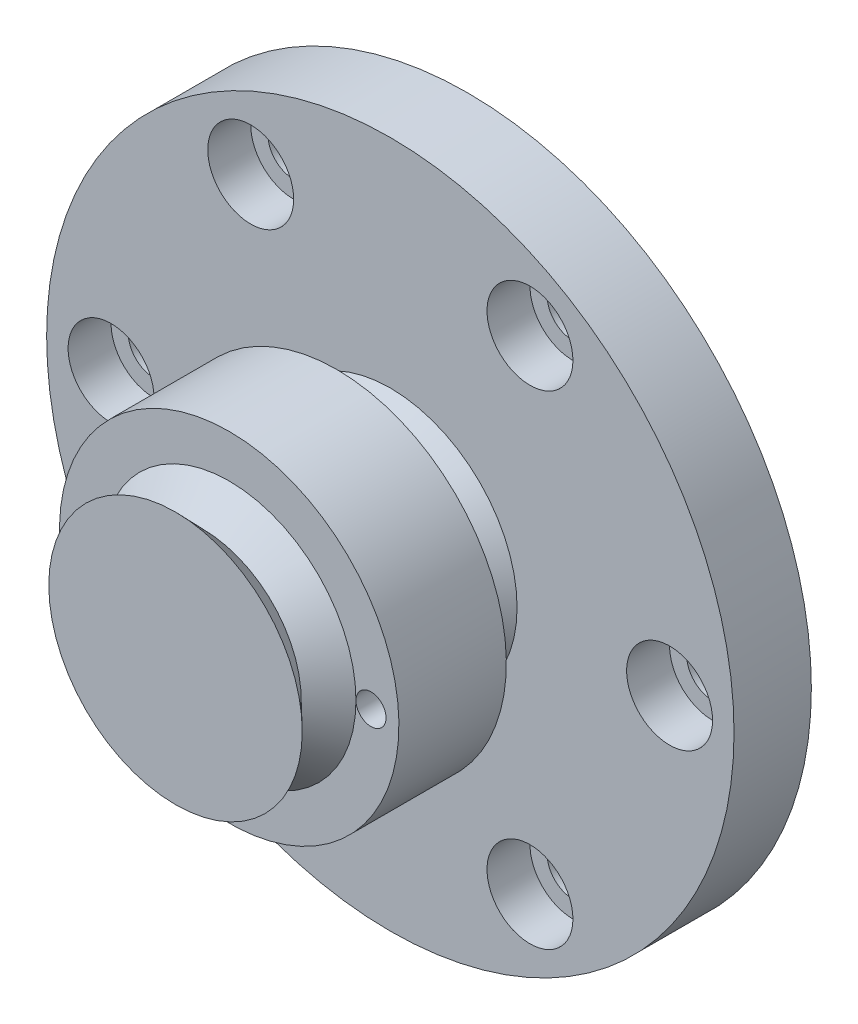
from build123d import *

# Parameters (mm, degrees)
SKETCH_1_R          = 16
SKETCH_1_R_2        = 1.2
EXTRUDE_1_DEPTH     = 3.6
SKETCH_2_R          = 2
CUT_EXTRUDE_1_DEPTH = 2
SKETCH_3_R          = 1
CUT_EXTRUDE_2_DEPTH = 2
SKETCH_4_R          = 7.9
EXTRUDE_2_DEPTH     = 10
SKETCH_6_R          = 0.7
CUT_EXTRUDE_3_DEPTH = 5


with BuildPart() as part:
    # 스케치1 → 보스-돌출1 (new body)
    with BuildSketch(Plane.XY):
        Circle(SKETCH_1_R)
        with Locations((13, 0)):
            Circle(SKETCH_1_R_2, mode=Mode.SUBTRACT)
        with Locations((6.5, -11.258330249)):
            Circle(SKETCH_1_R_2, mode=Mode.SUBTRACT)
        with Locations((-6.5, -11.258330249)):
            Circle(SKETCH_1_R_2, mode=Mode.SUBTRACT)
        with Locations((-13, 0)):
            Circle(SKETCH_1_R_2, mode=Mode.SUBTRACT)
        with Locations((-6.5, 11.258330249)):
            Circle(SKETCH_1_R_2, mode=Mode.SUBTRACT)
        with Locations((6.5, 11.258330249)):
            Circle(SKETCH_1_R_2, mode=Mode.SUBTRACT)
    extrude(amount=EXTRUDE_1_DEPTH)

    # 스케치2 → 컷-돌출1 (cut)
    with BuildSketch(Plane.XY.offset(3.6)):
        with Locations((13, 0)):
            Circle(SKETCH_2_R)
        with Locations((6.5, -11.258330249)):
            Circle(SKETCH_2_R)
        with Locations((-6.5, -11.258330249)):
            Circle(SKETCH_2_R)
        with Locations((-13, 0)):
            Circle(SKETCH_2_R)
        with Locations((-6.5, 11.258330249)):
            Circle(SKETCH_2_R)
        with Locations((6.5, 11.258330249)):
            Circle(SKETCH_2_R)
    extrude(amount=-CUT_EXTRUDE_1_DEPTH, mode=Mode.SUBTRACT)

    # 스케치3 → 컷-돌출2 (cut)
    with BuildSketch(Plane(origin=(0, 0, 0), x_dir=(-1, 0, 0), z_dir=(0, 0, -1))):
        with Locations((-6, 0)):
            Circle(SKETCH_3_R)
        with Locations((6, 0)):
            Circle(SKETCH_3_R)
    extrude(amount=-CUT_EXTRUDE_2_DEPTH, mode=Mode.SUBTRACT)

    # 스케치4 → 보스-돌출2 (add)
    with BuildSketch(Plane.XY.offset(3.6)):
        Circle(SKETCH_4_R)
    extrude(amount=EXTRUDE_2_DEPTH)

    # 스케치5 → 컷-회전1 (revolve, cut)
    with BuildSketch(Plane(origin=(0, 0, 0), x_dir=(0, 0, -1), z_dir=(1, 0, 0))):
        Polygon((-13.6, 7.9), (-13.6, 5.9), (-12.35, 4.6), (-11.1, 5.9), (-11.1, 7.9), align=None)
        Polygon((-6.1, 7.9), (-3.6, 7.9), (-3.6, 5.9), (-4.85, 4.6), (-6.1, 5.9), align=None)
    revolve(axis=Axis((0, 0, 0), (0, 0, 1)), mode=Mode.SUBTRACT)

    # 스케치6 → 컷-돌출3 (cut)
    with BuildSketch(Plane.XY.offset(11.1)):
        with Locations((6.6, 0)):
            Circle(SKETCH_6_R)
    extrude(amount=-CUT_EXTRUDE_3_DEPTH, mode=Mode.SUBTRACT)


solid = part.part
